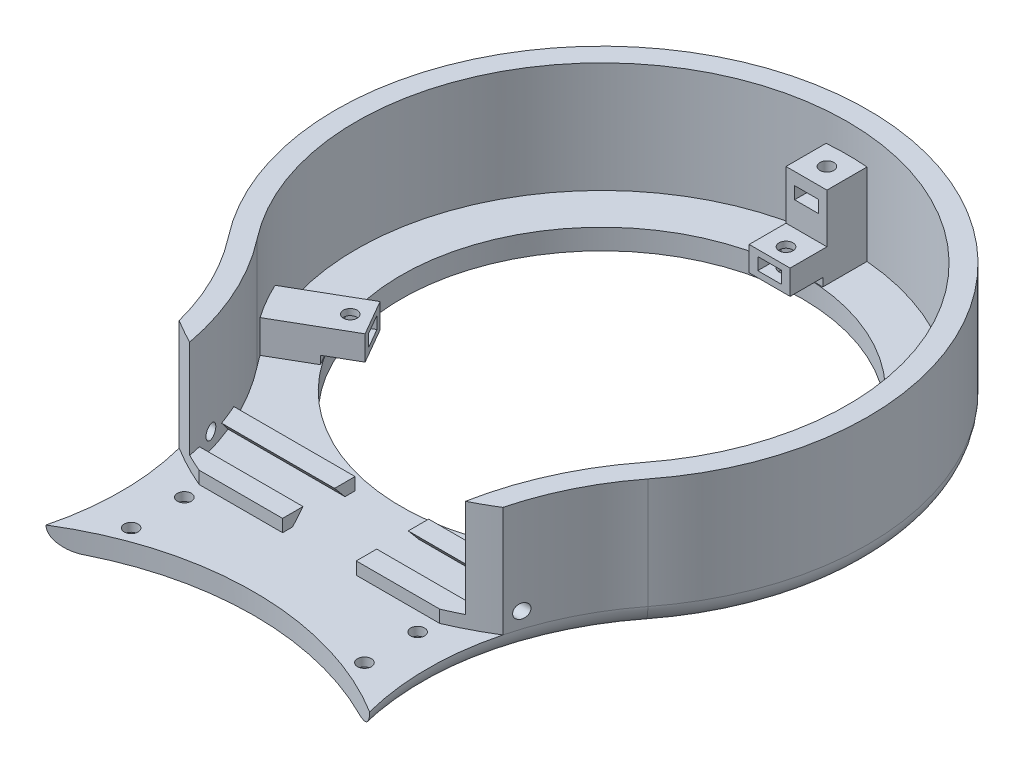
from build123d import *

# Parameters (mm, degrees)
SALIENTE_EXTRUIR1_DEPTH      = 32
CORTAR_EXTRUIR1_DEPTH        = 27
CROQUIS3_R                   = 62.5
CORTAR_EXTRUIR2_DEPTH        = 29
CROQUIS4_R                   = 18
SALIENTE_EXTRUIR2_DEPTH      = 8
CROQUIS5_R                   = 49
CORTAR_EXTRUIR3_DEPTH        = 5
SALIENTE_EXTRUIR3_START      = 5
SALIENTE_EXTRUIR3_DEPTH      = 5
SALIENTE_EXTRUIR4_REACH      = 167.907
SALIENTE_EXTRUIR4_END_RADIUS = 70
SALIENTE_EXTRUIR5_DEPTH      = 5
CROQUIS9_R                   = 1.7
CORTAR_EXTRUIR4_DEPTH        = 8
CORTAR_EXTRUIR5_DEPTH        = 1.5
MATRIZC1_COUNT               = 3
SALIENTE_EXTRUIR6_START      = 12
SALIENTE_EXTRUIR6_DEPTH      = 12
CROQUIS12_R                  = 1.7
CORTAR_EXTRUIR6_DEPTH        = 12
CORTAR_EXTRUIR7_DEPTH        = 1.5
CORTAR_EXTRUIR7_DEPTH_BACK   = 1.5
CORTAR_EXTRUIR8_DEPTH        = 58
CORTAR_EXTRUIR8_DEPTH_BACK   = 58.5
CROQUIS14_R                  = 1.7
CROQUIS15_R                  = 1.7
CORTAR_EXTRUIR9_DEPTH        = 11.5
CROQUIS16_R                  = 2.95
CORTAR_EXTRUIR10_DEPTH       = 2.9
REDONDEO1_R                  = 5
CROQUIS17_R                  = 4.2
CORTAR_EXTRUIR11_DEPTH       = 1.1
SALIENTE_EXTRUIR7_DEPTH      = 3
SALIENTE_EXTRUIR7_DEPTH_BACK = 3
CORTAR_EXTRUIR12_START       = -35
CROQUIS19_R                  = 75
CORTAR_EXTRUIR12_DEPTH       = 35
CORTAR_EXTRUIR13_DEPTH       = 27


with BuildPart() as part:
    # Croquis1 → Saliente-Extruir1 (new body)
    with BuildSketch(Plane(origin=(0, 0, 0), x_dir=(1, 0, 0), z_dir=(0, 1, 0))):
        with BuildLine():
            ThreePointArc((51.23475383, 40), (0, 145), (-51.23475383, 40))
            ThreePointArc((-51.23475383, 40), (-37.46950766, 0), (-51.23475383, -40))
            ThreePointArc((-51.23475383, -40), (0, -145), (51.23475383, -40))
            ThreePointArc((51.23475383, -40), (37.46950766, 0), (51.23475383, 40))
        make_face()
    extrude(amount=SALIENTE_EXTRUIR1_DEPTH)

    # Croquis2 → Cortar-Extruir1 (cut)
    with BuildSketch(Plane(origin=(0, 32, 0), x_dir=(1, 0, 0), z_dir=(0, 1, 0))):
        with BuildLine():
            ThreePointArc((47.29361892, 43.076923077), (0, 140), (-47.29361892, 43.076923077))
            ThreePointArc((-47.29361892, 43.076923077), (-32.46950766, 0), (-47.29361892, -43.076923077))
            ThreePointArc((-47.29361892, -43.076923077), (0, -140), (47.29361892, -43.076923077))
            ThreePointArc((47.29361892, -43.076923077), (32.46950766, 0), (47.29361892, 43.076923077))
        make_face()
    extrude(amount=-CORTAR_EXTRUIR1_DEPTH, mode=Mode.SUBTRACT)

    # Croquis3 → Cortar-Extruir2 (cut)
    with BuildSketch(Plane(origin=(0, 32, 0), x_dir=(1, 0, 0), z_dir=(0, 1, 0))):
        with Locations((0, -80)):
            Circle(CROQUIS3_R)
    extrude(amount=-CORTAR_EXTRUIR2_DEPTH, mode=Mode.SUBTRACT)

    # Croquis4 → Saliente-Extruir2 (add)
    with BuildSketch(Plane(origin=(0, 3, 0), x_dir=(1, 0, 0), z_dir=(0, 1, 0))):
        with Locations((0, -80)):
            Circle(CROQUIS4_R)
    extrude(amount=SALIENTE_EXTRUIR2_DEPTH)

    # Croquis5 → Cortar-Extruir3 (cut)
    with BuildSketch(Plane.XZ):
        with Locations((0, -80)):
            Circle(CROQUIS5_R)
    extrude(amount=-CORTAR_EXTRUIR3_DEPTH, mode=Mode.SUBTRACT)

    # Croquis6 → Saliente-Extruir3 (add)
    with BuildSketch(Plane(origin=(0, 5, 0), x_dir=(1, 0, 0), z_dir=(0, 1, 0)).offset(SALIENTE_EXTRUIR3_START)):
        with BuildLine():
            ThreePointArc((-33.685420375, 12.990355514), (0, 5), (33.685420375, 12.990355514))
            ThreePointArc((33.685420375, 12.990355514), (32.46950766, 0), (33.685420375, -12.990355514))
            ThreePointArc((33.685420375, -12.990355514), (0, -5), (-33.685420375, -12.990355514))
            ThreePointArc((-33.685420375, -12.990355514), (-32.46950766, 0), (-33.685420375, 12.990355514))
        make_face()
    extrude(amount=-SALIENTE_EXTRUIR3_DEPTH)

    # Saliente-Extruir4: up to this cylinder (the profile starts outside it)
    saliente_extruir4_end = Plane(origin=(102.46950766, 6.69285, 0), z_dir=(0, 1, 0)) * Cylinder(SALIENTE_EXTRUIR4_END_RADIUS, 476.814, mode=Mode.PRIVATE)
    # Croquis7 → Saliente-Extruir4 (add, up to the surface)
    with BuildSketch(Plane(origin=(9, 0, 0), x_dir=(0, 0, -1), z_dir=(1, 0, 0)), mode=Mode.PRIVATE) as saliente_extruir4_sk1:
        Polygon((11, 8.038971661), (11, 5), (13.45, 5), (16, 8.038971661), align=None)
    saliente_extruir4_tool1 = extrude(saliente_extruir4_sk1.sketch, amount=SALIENTE_EXTRUIR4_REACH, mode=Mode.PRIVATE) - saliente_extruir4_end
    # Croquis7 → Saliente-Extruir4 (add, up to the surface)
    with BuildSketch(Plane(origin=(9, 0, 0), x_dir=(0, 0, -1), z_dir=(1, 0, 0)), mode=Mode.PRIVATE) as saliente_extruir4_sk2:
        Polygon((23.7, 8.038971661), (28.7, 8.038971661), (28.7, 5), (26.25, 5), align=None)
    saliente_extruir4_tool2 = extrude(saliente_extruir4_sk2.sketch, amount=SALIENTE_EXTRUIR4_REACH, mode=Mode.PRIVATE) - saliente_extruir4_end
    saliente_extruir4 = saliente_extruir4_tool1.solids().sort_by_distance((9, 6.69285, -12.935235))[0] + saliente_extruir4_tool2.solids().sort_by_distance((9, 6.69285, -26.764765))[0]
    add(saliente_extruir4)

    # Simetría1: Saliente-Extruir4 across plane
    add(saliente_extruir4.mirror(Plane(origin=(0, 0, 0), x_dir=(0, 0, 1), z_dir=(1, 0, 0))))

    # Croquis8 → Saliente-Extruir5 (add, symmetric)
    with BuildSketch(Plane(origin=(0, 0, 0), x_dir=(0, 0, -1), z_dir=(1, 0, 0))):
        Polygon((121, 13), (141, 13), (141, 5), (129, 5), (129, 7), (121, 7), align=None)
    saliente_extruir5 = extrude(amount=SALIENTE_EXTRUIR5_DEPTH, both=True)

    # Croquis9 → Cortar-Extruir4 (cut)
    with BuildSketch(Plane(origin=(0, 13, 0), x_dir=(1, 0, 0), z_dir=(0, 1, 0))):
        with Locations((0, 125)):
            Circle(CROQUIS9_R)
    cortar_extruir4 = extrude(amount=-CORTAR_EXTRUIR4_DEPTH, mode=Mode.SUBTRACT)

    # Croquis10 → Cortar-Extruir5 (cut, symmetric)
    with BuildSketch(Plane(origin=(0, 10, 0), x_dir=(1, 0, 0), z_dir=(0, 1, 0))):
        Polygon((-2.901185103, 123.325), (-2.901185103, 116.675), (2.901185103, 116.675), (2.901185103, 123.325), (2.901185103, 126.675), (0, 128.35), (-2.901185103, 126.675), align=None)
    cortar_extruir5 = extrude(amount=CORTAR_EXTRUIR5_DEPTH, both=True, mode=Mode.SUBTRACT)

    # MatrizC1: Saliente-Extruir5, Cortar-Extruir4, Cortar-Extruir5 ×3 about axis
    matrizc1_axis = Axis((0, 5, -80), (0, -1, 0))
    add([saliente_extruir5.rotate(matrizc1_axis, i * 360 / MATRIZC1_COUNT) for i in range(1, MATRIZC1_COUNT)])
    add([cortar_extruir4.rotate(matrizc1_axis, i * 360 / MATRIZC1_COUNT) for i in range(1, MATRIZC1_COUNT)], mode=Mode.SUBTRACT)
    add([cortar_extruir5.rotate(matrizc1_axis, i * 360 / MATRIZC1_COUNT) for i in range(1, MATRIZC1_COUNT)], mode=Mode.SUBTRACT)

    # Croquis11 → Saliente-Extruir6 (add)
    with BuildSketch(Plane(origin=(0, 13, 0), x_dir=(1, 0, 0), z_dir=(0, 1, 0)).offset(SALIENTE_EXTRUIR6_START)):
        with BuildLine():
            Line((5, 130), (-5, 130))
            Line((-5, 130), (-5, 139.791303716))
            ThreePointArc((-5, 139.791303716), (0, 140), (5, 139.791303716))
            Line((5, 139.791303716), (5, 130))
        make_face()
    extrude(amount=-SALIENTE_EXTRUIR6_DEPTH)

    # Croquis12 → Cortar-Extruir6 (cut)
    with BuildSketch(Plane(origin=(0, 25, 0), x_dir=(1, 0, 0), z_dir=(0, 1, 0))):
        with Locations((0, 135)):
            Circle(CROQUIS12_R)
    extrude(amount=-CORTAR_EXTRUIR6_DEPTH, mode=Mode.SUBTRACT)

    # Croquis13 → Cortar-Extruir7 (cut, two sides: drawn at the far end of the back side and taken through both)
    with BuildSketch(Plane(origin=(0, 20.5, 0), x_dir=(1, 0, 0), z_dir=(0, 1, 0)).offset(-CORTAR_EXTRUIR7_DEPTH_BACK)):
        Polygon((-2.901185103, 133.325), (-2.901185103, 126.675), (2.901185103, 126.675), (2.901185103, 133.325), (2.901185103, 136.675), (0, 138.35), (-2.901185103, 136.675), align=None)
    extrude(amount=CORTAR_EXTRUIR7_DEPTH + CORTAR_EXTRUIR7_DEPTH_BACK, mode=Mode.SUBTRACT)

    # Croquis14 → Cortar-Extruir8 (cut, two sides: drawn at the far end of the back side and taken through both)
    with BuildSketch(Plane(origin=(0, 0, 0), x_dir=(0, 0, -1), z_dir=(1, 0, 0)).offset(-CORTAR_EXTRUIR8_DEPTH_BACK)):
        with Locations((19.85, 8.8)):
            Circle(CROQUIS14_R)
    extrude(amount=CORTAR_EXTRUIR8_DEPTH + CORTAR_EXTRUIR8_DEPTH_BACK, mode=Mode.SUBTRACT)

    # Croquis15 → Cortar-Extruir9 (cut)
    with BuildSketch(Plane.XZ):
        with Locations((-28.5, 6.5)):
            Circle(CROQUIS15_R)
        with Locations((-28.5, -6.5)):
            Circle(CROQUIS15_R)
        with Locations((28.5, 6.5)):
            Circle(CROQUIS15_R)
        with Locations((28.5, -6.5)):
            Circle(CROQUIS15_R)
    extrude(amount=-CORTAR_EXTRUIR9_DEPTH, mode=Mode.SUBTRACT)

    # Croquis16 → Cortar-Extruir10 (cut)
    with BuildSketch(Plane.XZ):
        with Locations((-28.5, 6.5)):
            Circle(CROQUIS16_R)
        with Locations((-28.5, -6.5)):
            Circle(CROQUIS16_R)
        with Locations((28.5, 6.5)):
            Circle(CROQUIS16_R)
        with Locations((28.5, -6.5)):
            Circle(CROQUIS16_R)
    extrude(amount=-CORTAR_EXTRUIR10_DEPTH, mode=Mode.SUBTRACT)

    # Redondeo1
    redondeo1_edges = [part.edges().sort_by_distance(p)[0] for p in [
        (-37.46950766, 0, 0),
        (0, 0, 145),
        (0, 0, -145),
        (37.46950766, 0, 0),
    ]]
    fillet(redondeo1_edges, radius=REDONDEO1_R)

    # Croquis17 → Cortar-Extruir11 (cut)
    with BuildSketch(Plane.XZ):
        Circle(CROQUIS17_R)
        with Locations((0, -134.5)):
            Circle(CROQUIS17_R)
    extrude(amount=-CORTAR_EXTRUIR11_DEPTH, mode=Mode.SUBTRACT)

    # Croquis18 → Saliente-Extruir7 (add, two sides: drawn at the far end of the back side and taken through both)
    with BuildSketch(Plane.XY.offset(-SALIENTE_EXTRUIR7_DEPTH_BACK)):
        Polygon((-35, 27), (-35, 17), (-25, 27), align=None)
        Polygon((25, 27), (35, 27), (35, 17), align=None)
    extrude(amount=SALIENTE_EXTRUIR7_DEPTH + SALIENTE_EXTRUIR7_DEPTH_BACK)

    # Croquis19 → Cortar-Extruir12 (cut)
    with BuildSketch(Plane.XZ.offset(CORTAR_EXTRUIR12_START)):
        with Locations((0, 80)):
            Circle(CROQUIS19_R)
    extrude(amount=CORTAR_EXTRUIR12_DEPTH, mode=Mode.SUBTRACT)

    # Croquis20 → Cortar-Extruir13 (cut)
    with BuildSketch(Plane(origin=(0, 32, 0), x_dir=(1, 0, 0), z_dir=(0, 1, 0))):
        with BuildLine():
            Line((-50, 24.098300563), (-50, -24.098300563))
            ThreePointArc((-50, -24.098300563), (0, -5), (50, -24.098300563))
            Line((50, -24.098300563), (50, 24.098300563))
            ThreePointArc((50, 24.098300563), (0, 5), (-50, 24.098300563))
        make_face()
    extrude(amount=-CORTAR_EXTRUIR13_DEPTH, mode=Mode.SUBTRACT)


solid = part.part
